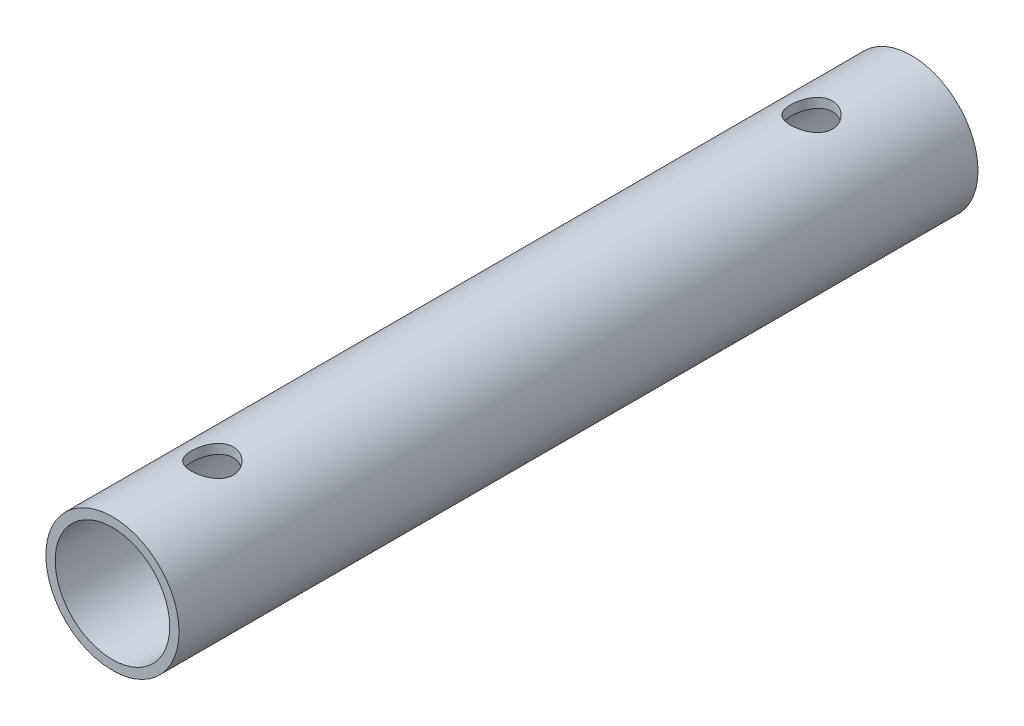
from build123d import *

# Parameters (mm, degrees)
SKETCH1_R               = 6.35
SKETCH1_R_2             = 5.461
EXTRUDE1_DEPTH          = 76.2
SKETCH2_R               = 2
CUT_EXTRUDE1_DEPTH      = 38.1
CUT_EXTRUDE1_DEPTH_BACK = 38.1


with BuildPart() as part:
    # Sketch1 → Extrude1 (new body)
    with BuildSketch(Plane.XY):
        Circle(SKETCH1_R)
        Circle(SKETCH1_R_2, mode=Mode.SUBTRACT)
    extrude(amount=EXTRUDE1_DEPTH)

    # Sketch2 → Cut-Extrude1 (cut, two sides)
    with BuildSketch(Plane(origin=(0, 0, 0), x_dir=(1, 0, 0), z_dir=(0, 1, 0))) as cut_extrude1_sk:
        with Locations(Location((0, -9.525, 0), (0, 0, 270))):  # turned: the seam where the file's is
            Circle(SKETCH2_R)
        with Locations(Location((0, -66.675, 0), (0, 0, 270))):  # turned: the seam where the file's is
            Circle(SKETCH2_R)
    extrude(amount=CUT_EXTRUDE1_DEPTH, mode=Mode.SUBTRACT)
    extrude(cut_extrude1_sk.sketch, amount=-CUT_EXTRUDE1_DEPTH_BACK, mode=Mode.SUBTRACT)


solid = part.part
